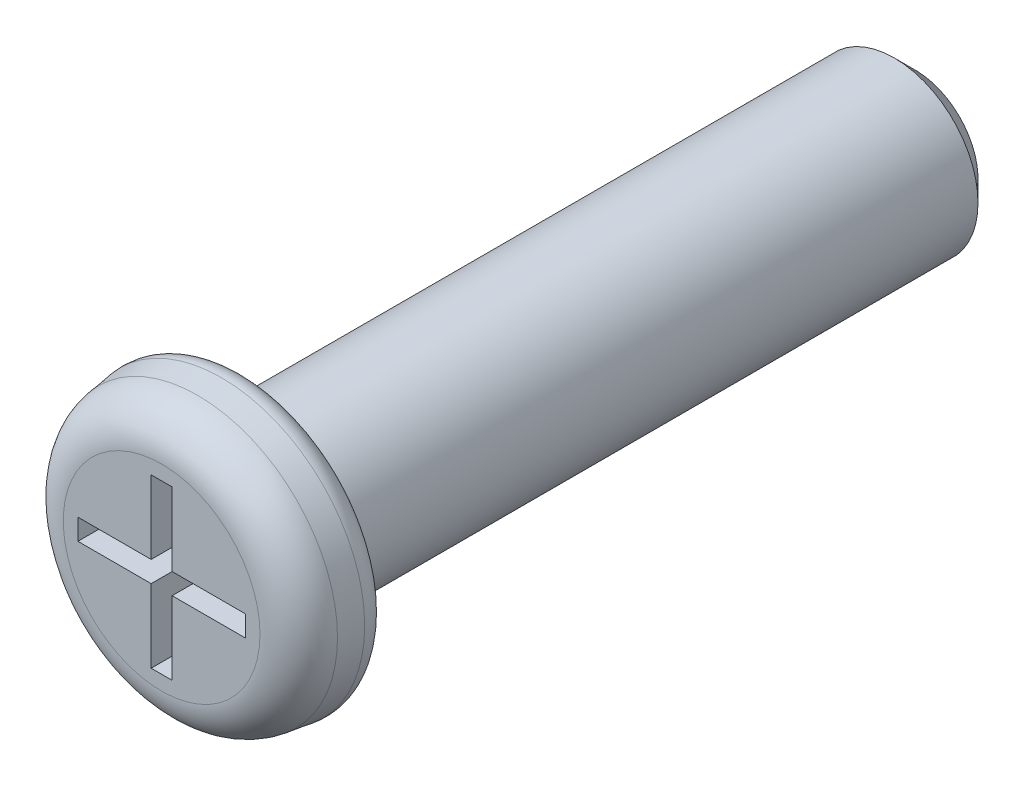
from build123d import *

# Parameters (mm, degrees)
ESQUISSE1_R             = 1.75
BASE_EXTRUSION_DEPTH    = 1
BASE_EXTRUSION_TAPER    = 8
CONG_1_R                = 0.5
ESQUISSE2_R             = 1
BOSS_EXTRU_1_DEPTH      = 8
CHANFREIN1_SIZE         = 0.25
ENL_V_MAT_EXTRU_1_DEPTH = 0.5
CONG_2_R                = 0.25


with BuildPart() as part:
    # Esquisse1 → Base-Extrusion (new body)
    with BuildSketch(Plane.XY):
        Circle(ESQUISSE1_R)
    extrude(amount=BASE_EXTRUSION_DEPTH, taper=BASE_EXTRUSION_TAPER)

    # Congé1
    cong_1_edges = [part.edges().sort_by_distance(p)[0] for p in [
        (-1.609459165, 0, 1),
    ]]
    fillet(cong_1_edges, radius=CONG_1_R)

    # Esquisse2 → Boss.-Extru.1 (add)
    with BuildSketch(Plane(origin=(0, 0, 0), x_dir=(-1, 0, 0), z_dir=(0, 0, -1))):
        Circle(ESQUISSE2_R)
    extrude(amount=BOSS_EXTRU_1_DEPTH)

    # Chanfrein1
    chanfrein1_edges = [part.edges().sort_by_distance(p)[0] for p in [
        (1, 0, -8),
    ]]
    chamfer(chanfrein1_edges, length=CHANFREIN1_SIZE)

    # Esquisse3 → Enlèv. mat.-Extru.1 (cut)
    with BuildSketch(Plane.XY.offset(1)):
        Polygon((-0.125, 1), (-0.125, 0.125), (-1, 0.125), (-1, -0.125), (-0.125, -0.125), (-0.125, -1), (0.125, -1), (0.125, -0.125), (1, -0.125), (1, 0.125), (0.125, 0.125), (0.125, 1), align=None)
    extrude(amount=-ENL_V_MAT_EXTRU_1_DEPTH, mode=Mode.SUBTRACT)

    # Congé2
    cong_2_edges = [part.edges().sort_by_distance(p)[0] for p in [
        (-1.75, 0, 0),
    ]]
    fillet(cong_2_edges, radius=CONG_2_R)


solid = part.part
